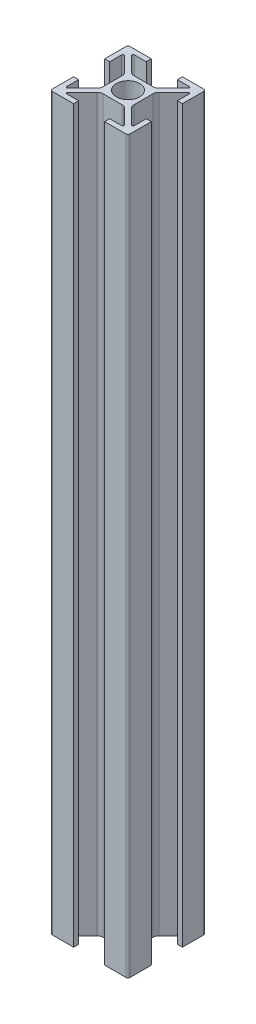
from build123d import *

# Parameters (mm, degrees)
ESBO_O1_R                = 3
RESSALTO_EXTRUS_O1_DEPTH = 188


with BuildPart() as part:
    # Esboço1 → Ressalto-extrusão1 (new body)
    with BuildSketch(Plane(origin=(0, 0, 0), x_dir=(1, 0, 0), z_dir=(0, 1, 0))):
        with BuildLine():
            Line((-7.056497116, 8.7), (-4, 8.7))
            Line((-4, 8.7), (-4, 10))
            Line((-4, 10), (-9.5, 10))
            ThreePointArc((-9.5, 10), (-9.853553391, 9.853553391), (-10, 9.5))
            Line((-10, 9.5), (-10, 4))
            Line((-10, 4), (-8.7, 4))
            Line((-8.7, 4), (-8.7, 7.056497116))
            ThreePointArc((-8.7, 7.056497116), (-8.51480503, 7.333660975), (-8.187867966, 7.26862915))
            Line((-8.187867966, 7.26862915), (-4.439339828, 3.520101013))
            ThreePointArc((-4.439339828, 3.520101013), (-4.114180701, 3.033465989), (-4, 2.459440841))
            Line((-4, 2.459440841), (-4, -2.459440841))
            ThreePointArc((-4, -2.459440841), (-4.114180701, -3.033465989), (-4.439339828, -3.520101013))
            Line((-4.439339828, -3.520101013), (-8.187867966, -7.26862915))
            ThreePointArc((-8.187867966, -7.26862915), (-8.51480503, -7.333660975), (-8.7, -7.056497116))
            Line((-8.7, -7.056497116), (-8.7, -4))
            Line((-8.7, -4), (-10, -4))
            Line((-10, -4), (-10, -9.5))
            ThreePointArc((-10, -9.5), (-9.853553391, -9.853553391), (-9.5, -10))
            Line((-9.5, -10), (-4, -10))
            Line((-4, -10), (-4, -8.7))
            Line((-4, -8.7), (-7.056497116, -8.7))
            ThreePointArc((-7.056497116, -8.7), (-7.333660975, -8.51480503), (-7.26862915, -8.187867966))
            Line((-7.26862915, -8.187867966), (-3.520101013, -4.439339828))
            ThreePointArc((-3.520101013, -4.439339828), (-3.033465989, -4.114180701), (-2.459440841, -4))
            Line((-2.459440841, -4), (2.459440841, -4))
            ThreePointArc((2.459440841, -4), (3.033465989, -4.114180701), (3.520101013, -4.439339828))
            Line((3.520101013, -4.439339828), (7.26862915, -8.187867966))
            ThreePointArc((7.26862915, -8.187867966), (7.333660975, -8.51480503), (7.056497116, -8.7))
            Line((7.056497116, -8.7), (4, -8.7))
            Line((4, -8.7), (4, -10))
            Line((4, -10), (9.5, -10))
            ThreePointArc((9.5, -10), (9.853553391, -9.853553391), (10, -9.5))
            Line((10, -9.5), (10, -4))
            Line((10, -4), (8.7, -4))
            Line((8.7, -4), (8.7, -7.056497116))
            ThreePointArc((8.7, -7.056497116), (8.51480503, -7.333660975), (8.187867966, -7.26862915))
            Line((8.187867966, -7.26862915), (4.439339828, -3.520101013))
            ThreePointArc((4.439339828, -3.520101013), (4.114180701, -3.033465989), (4, -2.459440841))
            Line((4, -2.459440841), (4, 2.459440841))
            ThreePointArc((4, 2.459440841), (4.114180701, 3.033465989), (4.439339828, 3.520101013))
            Line((4.439339828, 3.520101013), (8.187867966, 7.26862915))
            ThreePointArc((8.187867966, 7.26862915), (8.51480503, 7.333660975), (8.7, 7.056497116))
            Line((8.7, 7.056497116), (8.7, 4))
            Line((8.7, 4), (10, 4))
            Line((10, 4), (10, 9.5))
            ThreePointArc((10, 9.5), (9.853553391, 9.853553391), (9.5, 10))
            Line((9.5, 10), (4, 10))
            Line((4, 10), (4, 8.7))
            Line((4, 8.7), (7.056497116, 8.7))
            ThreePointArc((7.056497116, 8.7), (7.333660975, 8.51480503), (7.26862915, 8.187867966))
            Line((7.26862915, 8.187867966), (3.520101013, 4.439339828))
            ThreePointArc((3.520101013, 4.439339828), (3.033465989, 4.114180701), (2.459440841, 4))
            Line((2.459440841, 4), (-2.459440841, 4))
            ThreePointArc((-2.459440841, 4), (-3.033465989, 4.114180701), (-3.520101013, 4.439339828))
            Line((-3.520101013, 4.439339828), (-7.26862915, 8.187867966))
            ThreePointArc((-7.26862915, 8.187867966), (-7.333660975, 8.51480503), (-7.056497116, 8.7))
        make_face()
        Circle(ESBO_O1_R, mode=Mode.SUBTRACT)
    extrude(amount=RESSALTO_EXTRUS_O1_DEPTH)


solid = part.part
